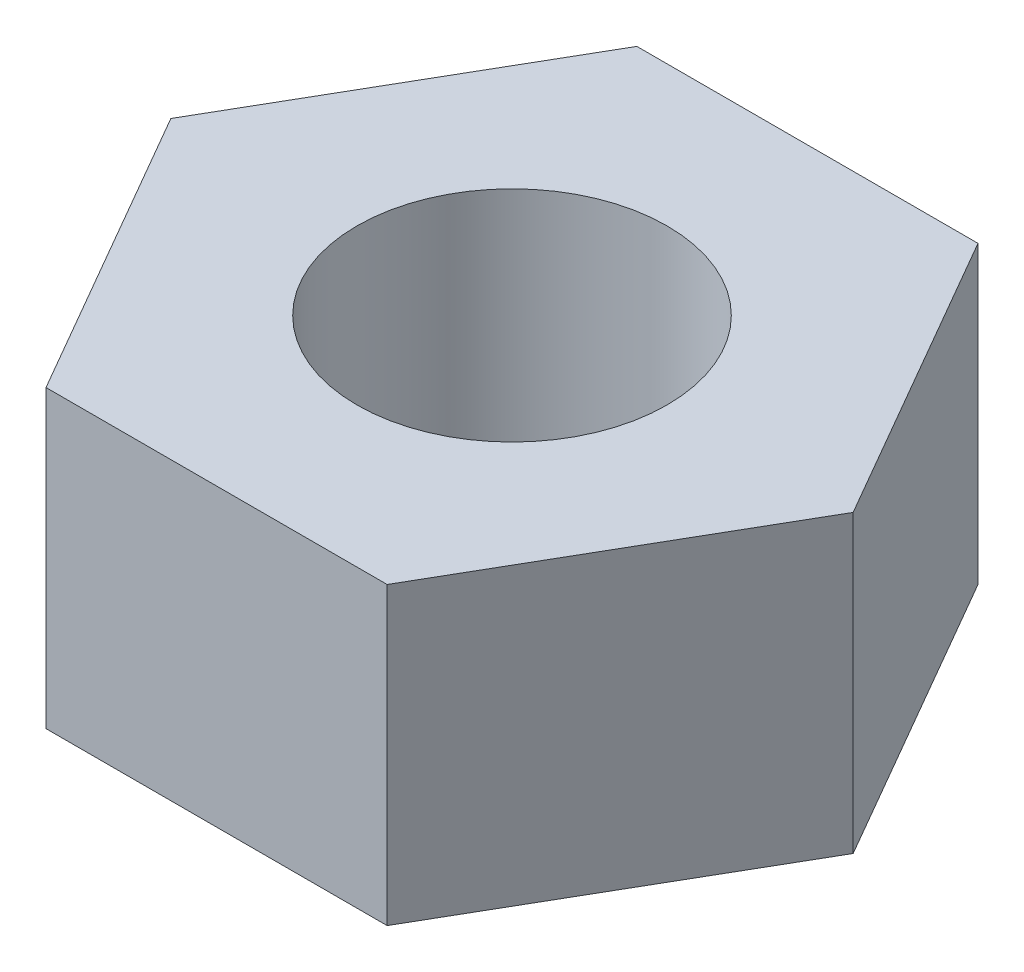
from build123d import *

# Parameters (mm, degrees)
CROQUIS1_R              = 2.1
SALIENTE_EXTRUIR1_DEPTH = 4


with BuildPart() as part:
    # Croquis1 → Saliente-Extruir1 (new body)
    with BuildSketch(Plane(origin=(0, 0, 0), x_dir=(1, 0, 0), z_dir=(0, 1, 0))):
        Polygon((-2.309401077, 4), (-4.618802154, 0), (-2.309401077, -4), (2.309401077, -4), (4.618802154, 0), (2.309401077, 4), align=None)
        Circle(CROQUIS1_R, mode=Mode.SUBTRACT)
    extrude(amount=SALIENTE_EXTRUIR1_DEPTH)


solid = part.part
